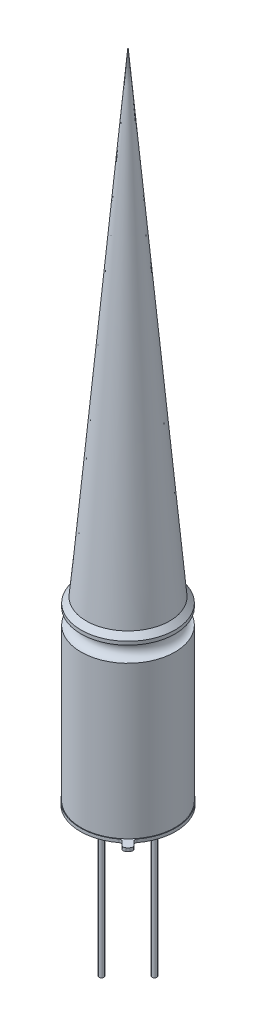
from build123d import *

# Parameters (mm, degrees)
SKETCH3_R           = 0.225
BOSS_EXTRUDE1_DEPTH = 13
BOSS_EXTRUDE2_DEPTH = 0.3
FILLET1_R           = 0.25


with BuildPart() as part:
    # Sketch2 → Revolve1 (revolve)
    with BuildSketch(Plane.XY):
        with BuildLine():
            Line((4.5, -0.5), (4, 0))
            Line((4, 0), (0, 0))
            Line((0, 0), (0, -17.2))
            Line((0, -17.2), (4.56, -17.2))
            Line((4.56, -17.2), (4.56, -16.9))
            Line((4.56, -16.9), (4.5, -16.9))
            Line((4.5, -16.9), (4.5, -2.33))
            ThreePointArc((4.5, -2.33), (3.75, -1.58), (4.5, -0.83))
            Line((4.5, -0.83), (4.5, -0.5))
        make_face()
    revolve(axis=Axis((0, 11.579317477, 0), (0, -1, 0)))

    # Sketch3 → Boss-Extrude1 (add)
    with BuildSketch(Plane.XZ.offset(17.2)):
        with Locations((-2.54, 0)):
            Circle(SKETCH3_R)
        with Locations((0, 2.54)):
            Circle(SKETCH3_R)
        with Locations((2.54, 0)):
            Circle(SKETCH3_R)
        with Locations((0, -2.54)):
            Circle(SKETCH3_R)
    extrude(amount=BOSS_EXTRUDE1_DEPTH)

    # Sketch4 → Boss-Extrude2 (add)
    with BuildSketch(Plane.XZ.offset(17.2)):
        with BuildLine():
            Line((2.929134872, 3.494820296), (3.636241653, 4.201927078))
            Line((3.636241653, 4.201927078), (4.201927078, 3.636241653))
            Line((4.201927078, 3.636241653), (3.494820296, 2.929134872))
            ThreePointArc((3.494820296, 2.929134872), (3.224406922, 3.224406922), (2.929134872, 3.494820296))
        make_face()
    extrude(amount=-BOSS_EXTRUDE2_DEPTH)

    # Fillet1
    fillet1_edges = [part.edges().sort_by_distance(p)[0] for p in [
        (4.201927078, -17.05, 3.636241653),
        (3.636241653, -17.05, 4.201927078),
        (2.929134872, -17.05, 3.494820296),
        (3.494820296, -17.05, 2.929134872),
    ]]
    fillet(fillet1_edges, radius=FILLET1_R)

    # Sketch6 → Revolve2 (revolve)
    with BuildSketch(Plane.XY):
        Polygon((0, 0), (0, 45.720209211), (4, 0), align=None)
    revolve(axis=Axis((0, 0, 0), (0, 1, 0)))


solid = part.part
